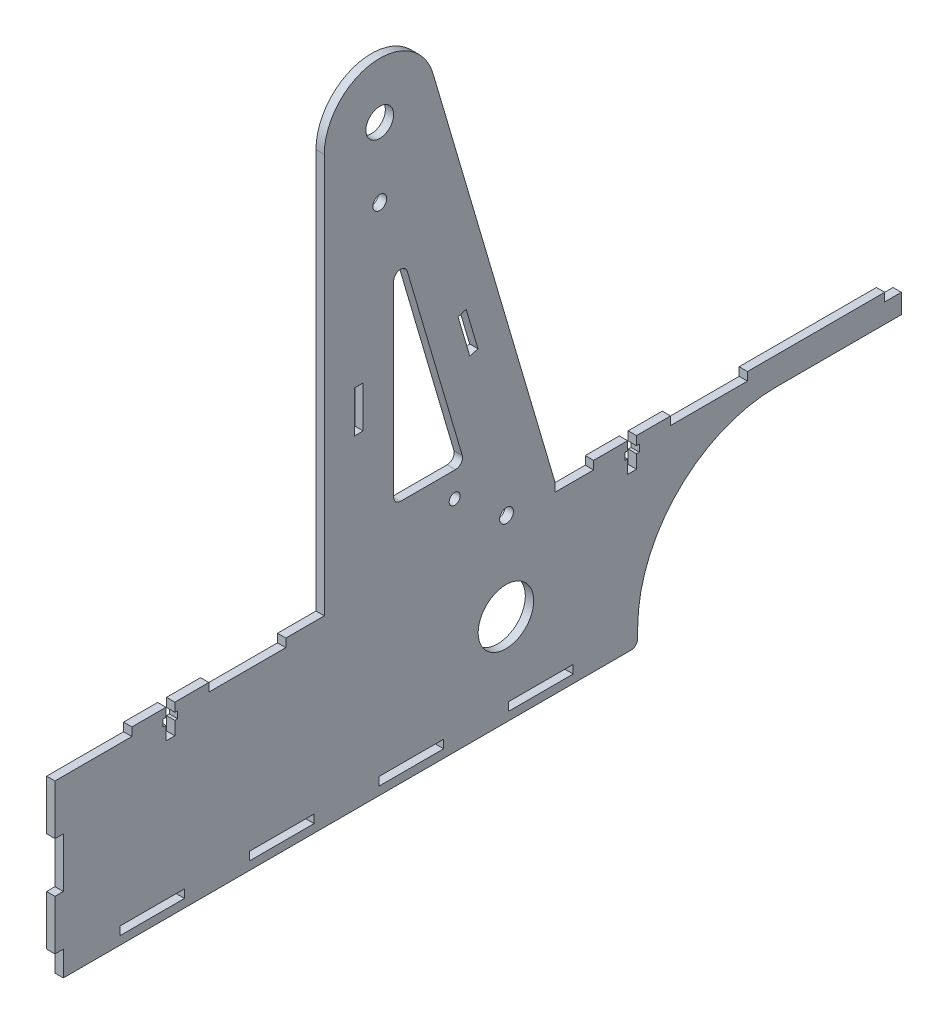
from build123d import *

# Parameters (mm, degrees)
BOSS_EXTRUDE1_DEPTH     = 3
SKETCH2_W               = 27.727272727
SKETCH2_H               = 3
SKETCH2_W_2             = 3
SKETCH2_H_2             = 18
SKETCH2_H_3             = 9
SKETCH2_W_3             = 23.343342349
SKETCH2_W_4             = 23.34334235
SKETCH2_W_5             = 6
CUT_EXTRUDE1_DEPTH      = 1
CUT_EXTRUDE1_DEPTH_BACK = 4
SKETCH3_W               = 3.2
SKETCH3_H               = 10.5
SKETCH3_W_2             = 5.2
SKETCH3_H_2             = 2.5
CUT_EXTRUDE2_DEPTH      = 1
CUT_EXTRUDE2_DEPTH_BACK = 4
FILLET1_R               = 2.5
SKETCH4_R               = 5
BOSS_EXTRUDE2_DEPTH     = 3
FILLET2_R               = 2.5
SKETCH5_R               = 2.5
SKETCH5_R_2             = 2
SKETCH5_R_3             = 10
SKETCH5_W               = 3.05
SKETCH5_H               = 15
CUT_EXTRUDE3_DEPTH      = 1
CUT_EXTRUDE3_DEPTH_BACK = 4


with BuildPart() as part:
    # Sketch1 → Boss-Extrude1 (new body)
    with BuildSketch(Plane(origin=(0, 0, 0), x_dir=(0, 0, -1), z_dir=(1, 0, 0))):
        with BuildLine():
            Line((-152.5, 33), (152.5, 33))
            Line((152.5, 33), (152.5, 23))
            Line((152.5, 23), (107.5, 23))
            ThreePointArc((107.5, 23), (72.144660941, 8.355339059), (57.5, -27))
            Line((57.5, -27), (57.5, -33))
            Line((57.5, -33), (-152.5, -33))
            Line((-152.5, -33), (-152.5, 33))
        make_face()
    extrude(amount=BOSS_EXTRUDE1_DEPTH)

    # Sketch2 → Cut-Extrude1 (cut, two sides)
    with BuildSketch(Plane(origin=(3, 0, 0), x_dir=(0, 0, -1), z_dir=(1, 0, 0))) as cut_extrude1_sk:
        with Locations((27.727272728, 31.5)):
            Rectangle(SKETCH2_W, SKETCH2_H)
        with Locations((83.181818182, 31.5)):
            Rectangle(SKETCH2_W, SKETCH2_H)
        with Locations((-138.636363636, 31.5)):
            Rectangle(SKETCH2_W, SKETCH2_H)
        with Locations((-83.181818182, 31.5)):
            Rectangle(SKETCH2_W, SKETCH2_H)
        with Locations((-27.727272728, 31.5)):
            Rectangle(SKETCH2_W, SKETCH2_H)
        with Locations((-151, 3)):
            Rectangle(SKETCH2_W_2, SKETCH2_H_2)
        with Locations((-151, -28.5)):
            Rectangle(SKETCH2_W_2, SKETCH2_H_3)
        with Locations((-117.484986475, -28.5)):
            Rectangle(SKETCH2_W_3, SKETCH2_H)
        with Locations((-70.798301777, -28.5)):
            Rectangle(SKETCH2_W_3, SKETCH2_H)
        with Locations((22.575067622, -28.5)):
            Rectangle(SKETCH2_W_4, SKETCH2_H)
        with Locations((149.5, 31.5)):
            Rectangle(SKETCH2_W_5, SKETCH2_H)
        with Locations((-24.111617078, -28.5)):
            Rectangle(SKETCH2_W_3, SKETCH2_H)
    extrude(amount=CUT_EXTRUDE1_DEPTH, mode=Mode.SUBTRACT)
    extrude(cut_extrude1_sk.sketch, amount=-CUT_EXTRUDE1_DEPTH_BACK, mode=Mode.SUBTRACT)

    # Sketch3 → Cut-Extrude2 (cut, two sides)
    with BuildSketch(Plane(origin=(3, 0, 0), x_dir=(0, 0, -1), z_dir=(1, 0, 0))) as cut_extrude2_sk:
        with Locations((-110.909090909, 27.75)):
            Rectangle(SKETCH3_W, SKETCH3_H)
        with Locations((55.454545455, 27.75)):
            Rectangle(SKETCH3_W, SKETCH3_H)
        with Locations((55.454545455, 28.575)):
            Rectangle(SKETCH3_W_2, SKETCH3_H_2)
        with Locations((-110.909090909, 28.575)):
            Rectangle(SKETCH3_W_2, SKETCH3_H_2)
    extrude(amount=CUT_EXTRUDE2_DEPTH, mode=Mode.SUBTRACT)
    extrude(cut_extrude2_sk.sketch, amount=-CUT_EXTRUDE2_DEPTH_BACK, mode=Mode.SUBTRACT)

    # Fillet1
    fillet1_edges = [part.edges().sort_by_distance(p)[0] for p in [
        (1.5, -33, -57.5),
    ]]
    fillet(fillet1_edges, radius=FILLET1_R)

    # Sketch4 → Boss-Extrude2 (add)
    with BuildSketch(Plane(origin=(0, 0, 0), x_dir=(0, 0, -1), z_dir=(1, 0, 0))):
        with BuildLine():
            Line((-55.454545455, 30), (-55.454545455, 177))
            ThreePointArc((-55.454545455, 177), (-38.304207087, 196.795944751), (-16.266602596, 182.641174423))
            Line((-16.266602596, 182.641174423), (27.727272727, 33))
            Line((27.727272727, 33), (27.727272727, 30))
            Line((27.727272727, 30), (-55.454545455, 30))
        make_face()
        with Locations((-35.454545455, 177)):
            Circle(SKETCH4_R, mode=Mode.SUBTRACT)
        Polygon((-30.454545455, 55), (-4.798665146, 55), (-30.454545455, 142.266148573), align=None, mode=Mode.SUBTRACT)
    extrude(amount=BOSS_EXTRUDE2_DEPTH)

    # Fillet2
    fillet2_edges = [part.edges().sort_by_distance(p)[0] for p in [
        (1.5, 55, 30.454545455),
        (1.5, 55, 4.798665146),
        (1.5, 142.266148573, 30.454545455),
    ]]
    fillet(fillet2_edges, radius=FILLET2_R)

    # Sketch5 → Cut-Extrude3 (cut, two sides)
    with BuildSketch(Plane(origin=(3, 0, 0), x_dir=(0, 0, -1), z_dir=(1, 0, 0))) as cut_extrude3_sk:
        with Locations((10.227172727, 31.5)):
            Circle(SKETCH5_R)
        with Locations((-35.454545455, 152)):
            Circle(SKETCH5_R)
        with Locations((-8.454545455, 46)):
            Circle(SKETCH5_R_2)
        with Locations((10, 0)):
            Circle(SKETCH5_R_3)
        Polygon((-3.003684653, 87.804874126), (-7.23456547, 102.195831269), (-4.308404184, 103.056110369), (-0.077523367, 88.665153225), align=None)
        with Locations((-42.954545455, 91.19961143)):
            Rectangle(SKETCH5_W, SKETCH5_H)
    extrude(amount=CUT_EXTRUDE3_DEPTH, mode=Mode.SUBTRACT)
    extrude(cut_extrude3_sk.sketch, amount=-CUT_EXTRUDE3_DEPTH_BACK, mode=Mode.SUBTRACT)


solid = part.part
